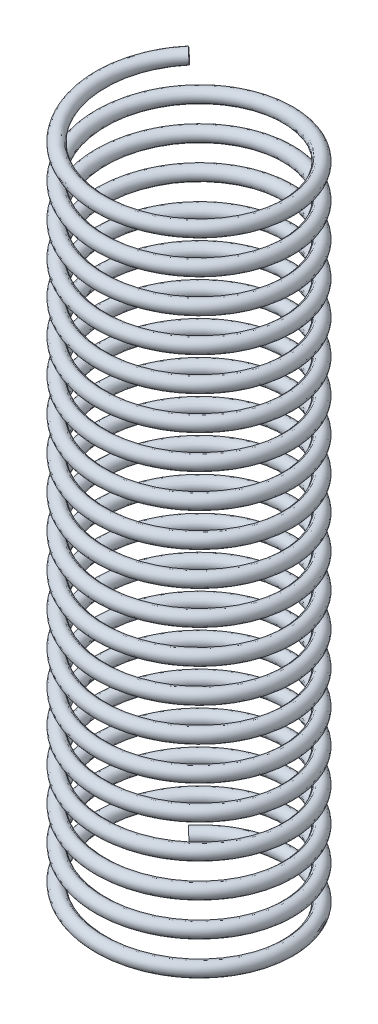
from build123d import *

# Parameters (mm, degrees)
SWEEP1_PITCH       = 5
SWEEP1_HEIGHT      = 100
SWEEP1_RADIUS      = 13.9
SWEEP1_START_ANGLE = -135
SWEEP1_PROFILE_R   = 1


with BuildPart() as part:
    # Sweep1: sweep along a helix
    with BuildLine() as sweep1_path:
        add(Helix(SWEEP1_PITCH, SWEEP1_HEIGHT, SWEEP1_RADIUS, center=(0, 0, 0), direction=(0, 1, 0), lefthand=True, mode=Mode.PRIVATE).rotate(Axis((0, 0, 0), (0, 1, 0)), SWEEP1_START_ANGLE))
    # Sweep1 profile (on start of the path) → Sweep1 (sweep)
    with BuildSketch(Plane(origin=(-9.828784258, 0, -9.828784258), x_dir=(-0.707106781, 0, -0.707106781), z_dir=(0.705950829, 0.057156389, -0.705950829))):
        Circle(SWEEP1_PROFILE_R)
    sweep(path=sweep1_path.line, is_frenet=True)


solid = part.part
